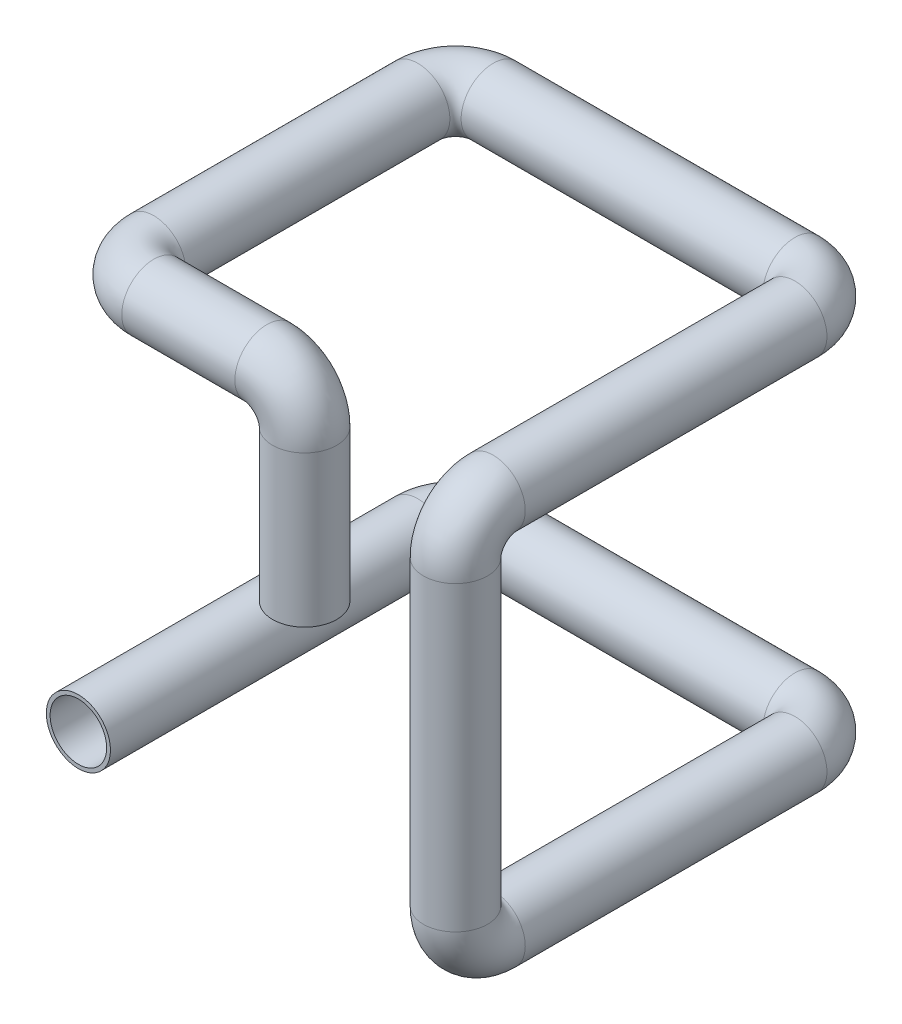
from build123d import *

# Parameters (mm, degrees)
SKETCH1_R   = 8.5
SKETCH1_R_2 = 7.5


with BuildPart() as part:
    # Sweep-Thin1: sweep along a curve in space
    with BuildLine() as sweep_thin1_path:
        Line((0, 0, 0), (0, 0, -90))
        ThreePointArc((0, 0, -90), (2.928932188, 0, -97.071067812), (10, 0, -100))
        Line((10, 0, -100), (90, 0, -100))
        ThreePointArc((90, 0, -100), (97.071067812, 0, -97.071067812), (100, 0, -90))
        Line((100, 0, -90), (100, 0, -10))
        ThreePointArc((100, 0, -10), (100, 2.928932188, -2.928932188), (100, 10, 0))
        Line((100, 10, 0), (100, 90, 0))
        ThreePointArc((100, 90, 0), (100, 97.071067812, -2.928932188), (100, 100, -10))
        Line((100, 100, -10), (100, 100, -90))
        ThreePointArc((100, 100, -90), (97.071067812, 100, -97.071067812), (90, 100, -100))
        Line((90, 100, -100), (10, 100, -100))
        ThreePointArc((10, 100, -100), (2.928932188, 100, -97.071067812), (0, 100, -90))
        Line((0, 100, -90), (0, 100, -20))
        ThreePointArc((0, 100, -20), (2.928932188, 100, -12.928932188), (10, 100, -10))
        Line((10, 100, -10), (40, 100, -10))
        ThreePointArc((40, 100, -10), (47.071067812, 97.071067812, -10), (50, 90, -10))
        Line((50, 90, -10), (50, 50, -10))
    # Sketch1 → Sweep-Thin1 (sweep)
    with BuildSketch(Plane.XY):
        Circle(SKETCH1_R)
        Circle(SKETCH1_R_2, mode=Mode.SUBTRACT)
    sweep(path=sweep_thin1_path.line)


solid = part.part
